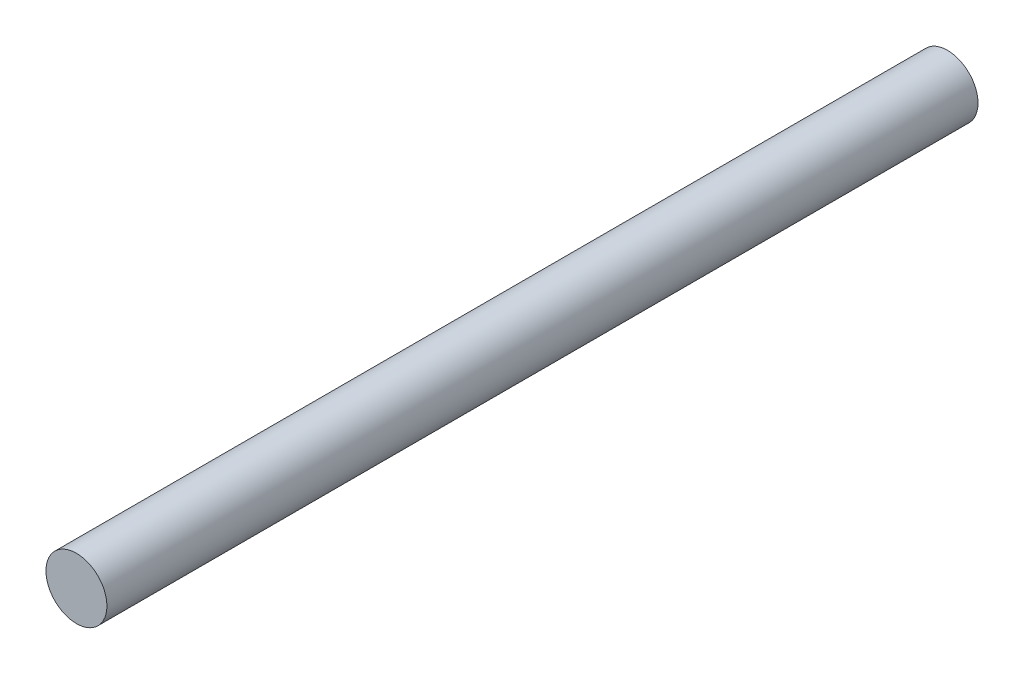
from build123d import *

# Parameters (mm, degrees)
SKETCH_1_R      = 1.4
EXTRUDE_1_DEPTH = 40


with BuildPart() as part:
    # 草图1 → 凸台-拉伸1 (new body)
    with BuildSketch(Plane.XY):
        Circle(SKETCH_1_R)
    extrude(amount=EXTRUDE_1_DEPTH)


solid = part.part
